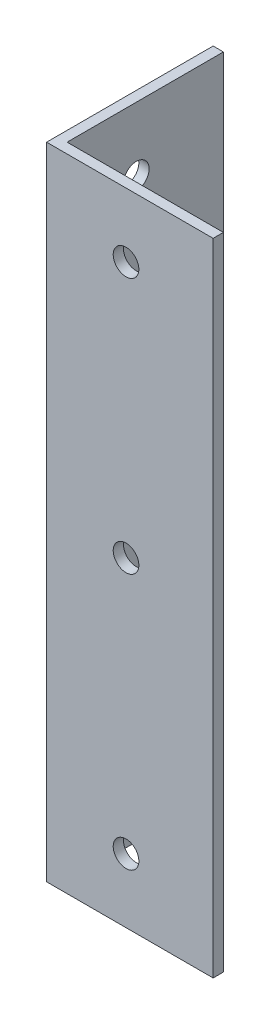
from build123d import *

# Parameters (mm, degrees)
EXTRUDE_1_DEPTH     = 250
SKETCH_6_R          = 5
CUT_EXTRUDE_1_DEPTH = 10
SKETCH_7_R          = 5
CUT_EXTRUDE_2_DEPTH = 10


with BuildPart() as part:
    # Эскиз1 → Вытянуть-Тонкостенный1 (new body)
    with BuildSketch(Plane(origin=(0, 0, 0), x_dir=(1, 0, 0), z_dir=(0, 1, 0))):
        Polygon((0, 65), (0, 0), (65, 0), (65, 4), (4, 4), (4, 65), align=None)
    extrude(amount=EXTRUDE_1_DEPTH)

    # Эскиз6 → Вырез-Вытянуть1 (cut)
    with BuildSketch(Plane.ZY):
        with Locations((-31, 25)):
            Circle(SKETCH_6_R)
        with Locations((-31, 125)):
            Circle(SKETCH_6_R)
        with Locations((-31, 225)):
            Circle(SKETCH_6_R)
    extrude(amount=-CUT_EXTRUDE_1_DEPTH, mode=Mode.SUBTRACT)

    # Эскиз7 → Вырез-Вытянуть2 (cut)
    with BuildSketch(Plane.XY):
        with Locations((31, 25)):
            Circle(SKETCH_7_R)
        with Locations((31, 125)):
            Circle(SKETCH_7_R)
        with Locations((31, 225)):
            Circle(SKETCH_7_R)
    extrude(amount=-CUT_EXTRUDE_2_DEPTH, mode=Mode.SUBTRACT)


solid = part.part
